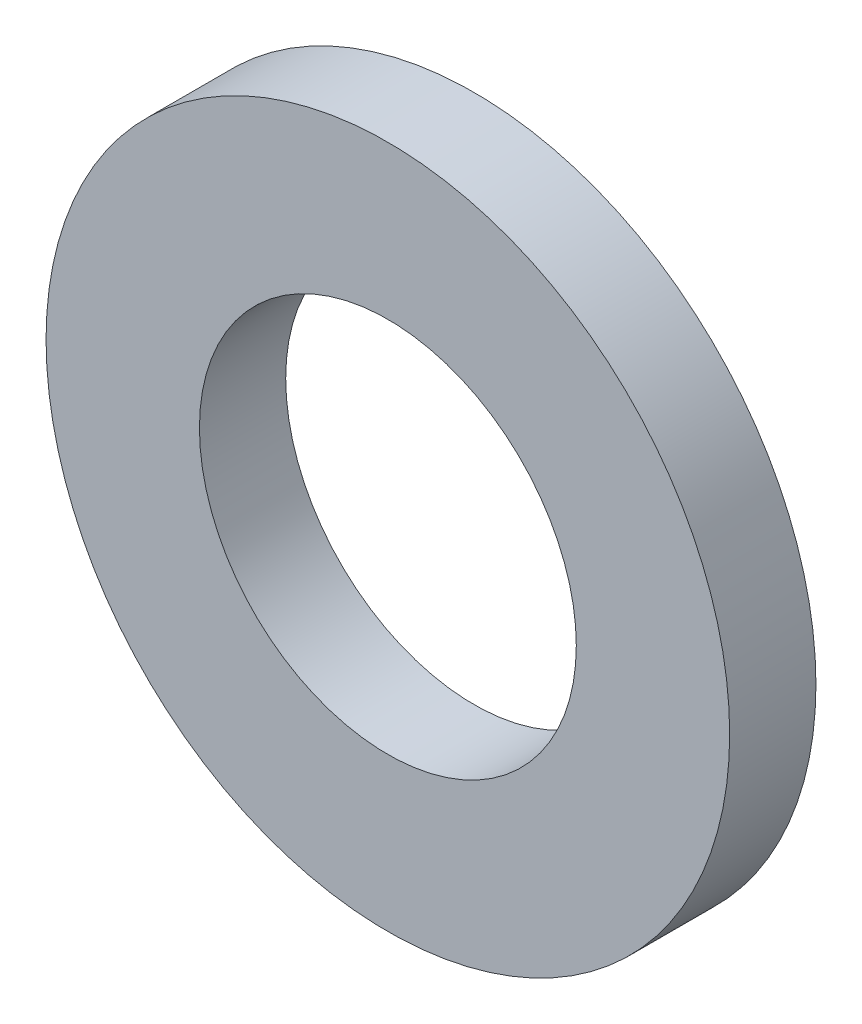
from build123d import *

# Parameters (mm, degrees)
SKETCH1_R      = 3.9624
SKETCH1_R_2    = 2.1844
EXTRUDE1_DEPTH = 1


with BuildPart() as part:
    # Sketch1 → Extrude1 (new body)
    with BuildSketch(Plane.XY):
        Circle(SKETCH1_R)
        Circle(SKETCH1_R_2, mode=Mode.SUBTRACT)
    extrude(amount=-EXTRUDE1_DEPTH)


solid = part.part
